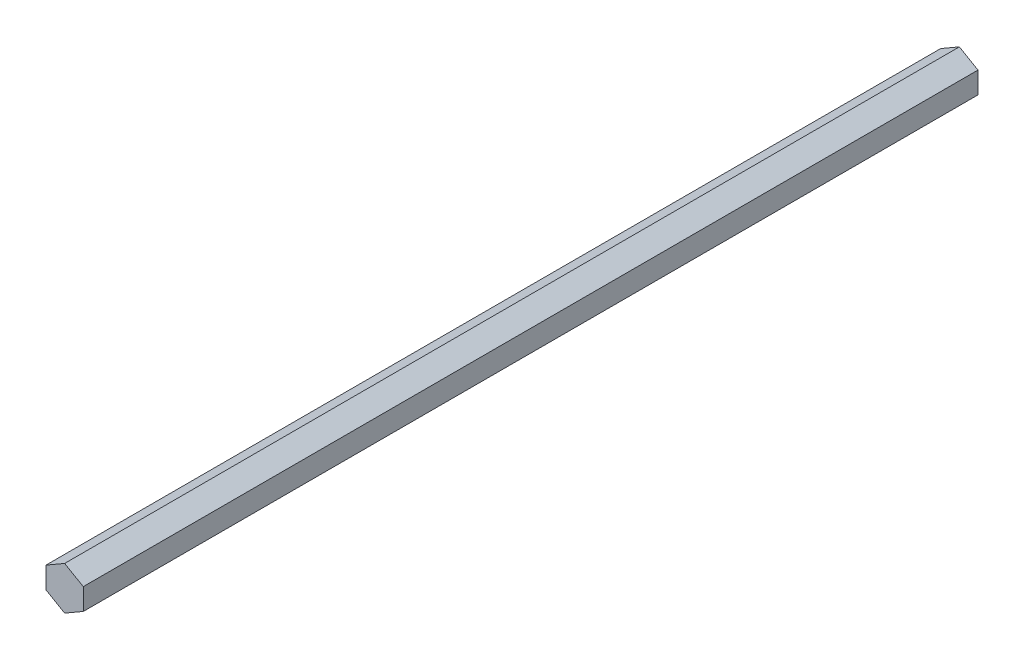
from build123d import *

# Parameters (mm, degrees)
BOSS_EXTRUDE1_DEPTH = 152.4


with BuildPart() as part:
    # Sketch3 → Boss-Extrude1 (new, symmetric)
    with BuildSketch(Plane.XY):
        Polygon((0, 7.332348419), (6.35, 3.666174209), (6.35, -3.666174209), (0, -7.332348419), (-6.35, -3.666174209), (-6.35, 3.666174209), align=None)
    extrude(amount=BOSS_EXTRUDE1_DEPTH, both=True)


solid = part.part
